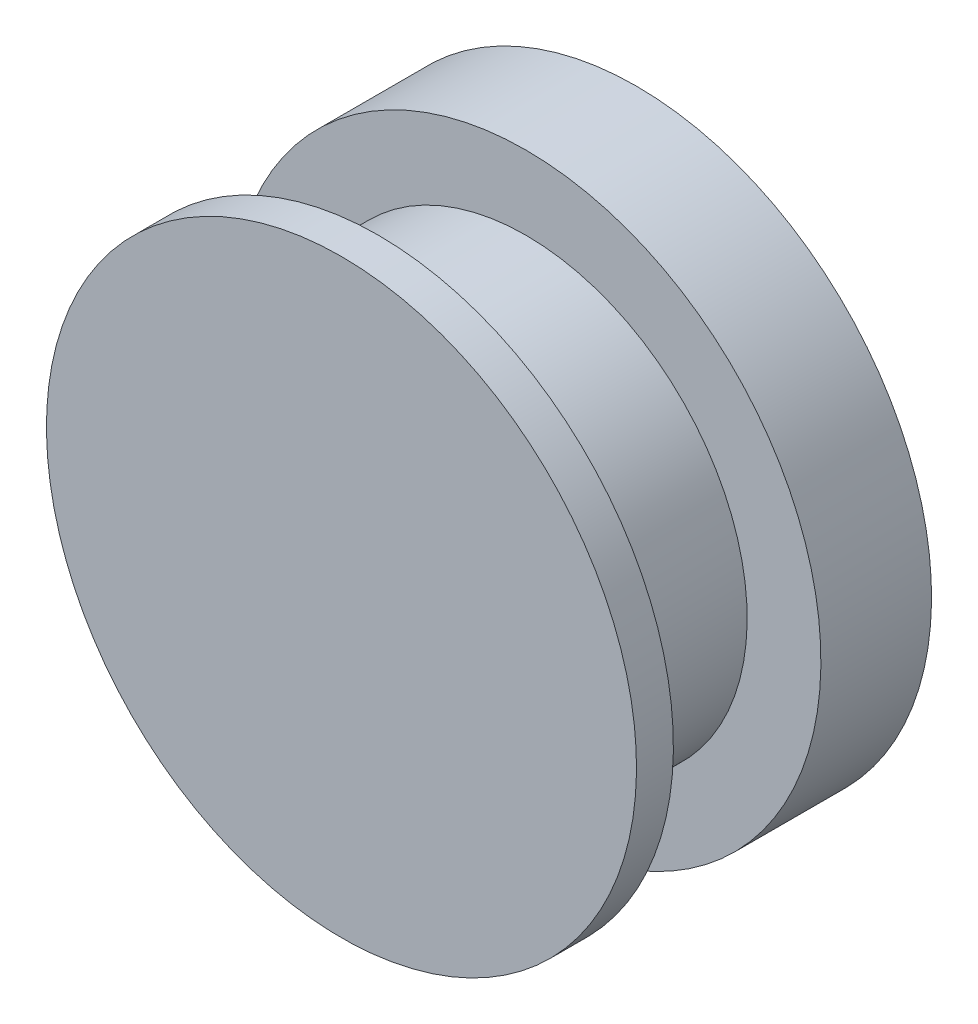
from build123d import *


with BuildPart() as part:
    # Sketch1 → Revolve1 (revolve)
    with BuildSketch(Plane(origin=(0, 0, 0), x_dir=(0, 0, -1), z_dir=(1, 0, 0))):
        Polygon((0, 0), (0, 2.032), (0.254, 2.032), (0.254, 1.524), (1.27, 1.524), (1.27, 2.032), (2.032, 2.032), (2.032, 0), align=None)
    revolve(axis=Axis((0, 0, -2.032), (0, 0, 1)))


solid = part.part
